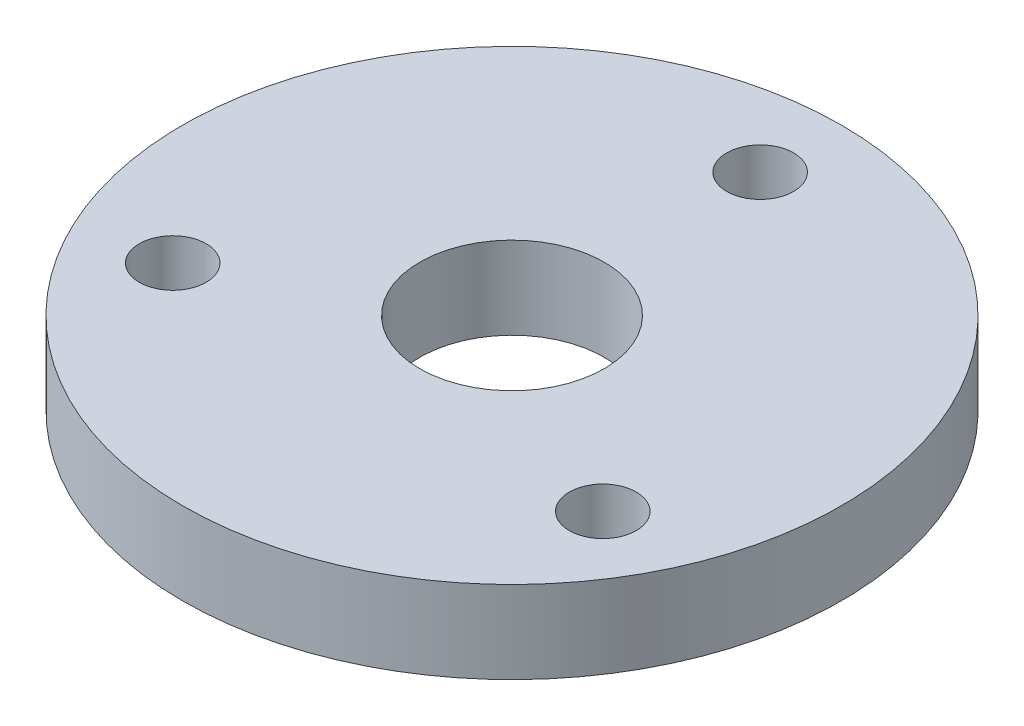
from build123d import *

# Parameters (mm, degrees)
SKETCH1_R           = 100
SKETCH1_R_2         = 28
SKETCH1_R_3         = 10.15
BOSS_EXTRUDE1_DEPTH = 12.5


with BuildPart() as part:
    # Sketch1 → Boss-Extrude1 (new body, symmetric)
    with BuildSketch(Plane(origin=(0, 0, 0), x_dir=(1, 0, 0), z_dir=(0, 1, 0))):
        Circle(SKETCH1_R)
        Circle(SKETCH1_R_2, mode=Mode.SUBTRACT)
        with Locations((0, 75.3)):
            Circle(SKETCH1_R_3, mode=Mode.SUBTRACT)
        with Locations((65.25, -37.7)):
            Circle(SKETCH1_R_3, mode=Mode.SUBTRACT)
        with Locations((-65.25, -37.7)):
            Circle(SKETCH1_R_3, mode=Mode.SUBTRACT)
    extrude(amount=BOSS_EXTRUDE1_DEPTH, both=True)


solid = part.part
